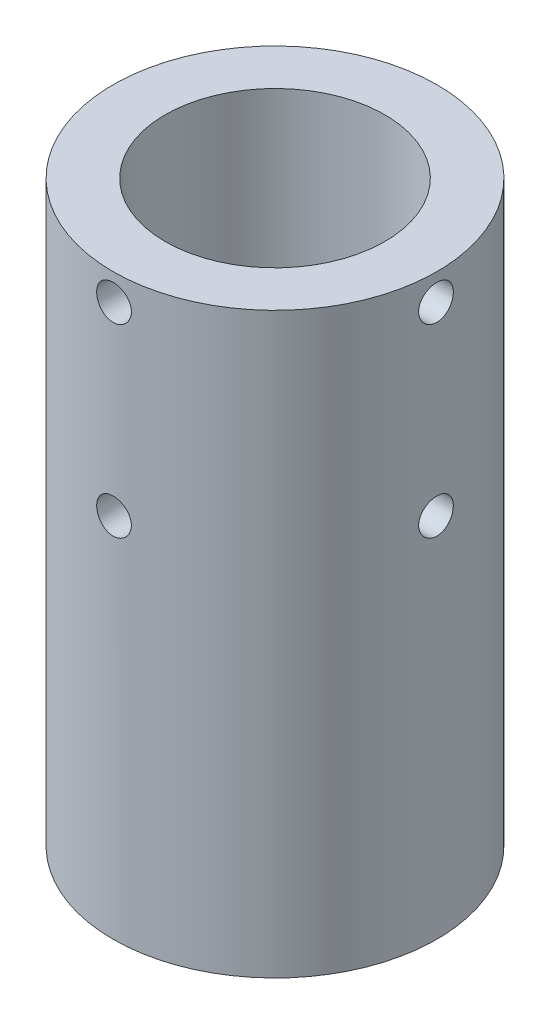
from build123d import *

# Parameters (mm, degrees)
SKETCH1_R           = 14
BOSS_EXTRUDE1_DEPTH = 50
CUT_EXTRUDE1_DEPTH  = 33
SKETCH3_R           = 9.5
CUT_EXTRUDE2_DEPTH  = 24.5
SKETCH5_R           = 1.5
CUT_EXTRUDE3_DEPTH  = 4.619168
CIRPATTERN1_COUNT   = 2
CIRPATTERN1_ANGLE   = 90


with BuildPart() as part:
    # Sketch1 → Boss-Extrude1 (new body)
    with BuildSketch(Plane(origin=(0, 0, 0), x_dir=(1, 0, 0), z_dir=(0, 1, 0))):
        with Locations(Location((0, 0, 0), (0, 0, 270))):  # turned: the seam where the file's is
            Circle(SKETCH1_R)
    extrude(amount=BOSS_EXTRUDE1_DEPTH)

    # Sketch2 → Cut-Extrude1 (cut)
    with BuildSketch(Plane(origin=(0, 0, 0), x_dir=(-1, 0, 0), z_dir=(0, -1, 0))):
        with BuildLine():
            Line((-2.397915762, -5.5), (2.397915762, -5.5))
            ThreePointArc((2.397915762, -5.5), (5.196152423, -3), (5.962097602, 0.673344034))
            Line((5.962097602, 0.673344034), (3.56418184, 4.826655966))
            ThreePointArc((3.56418184, 4.826655966), (0, 6), (-3.56418184, 4.826655966))
            Line((-3.56418184, 4.826655966), (-5.962097602, 0.673344034))
            ThreePointArc((-5.962097602, 0.673344034), (-5.196152423, -3), (-2.397915762, -5.5))
        make_face()
    extrude(amount=-CUT_EXTRUDE1_DEPTH, mode=Mode.SUBTRACT)

    # Sketch3 → Cut-Extrude2 (cut)
    with BuildSketch(Plane(origin=(0, 50, 0), x_dir=(1, 0, 0), z_dir=(0, 1, 0))):
        with Locations(Location((0, 0, 0), (0, 0, 270))):  # turned: the seam where the file's is
            Circle(SKETCH3_R)
    extrude(amount=-CUT_EXTRUDE2_DEPTH, mode=Mode.SUBTRACT)

    # Sketch5 → Cut-Extrude3 (cut)
    with BuildSketch(Plane(origin=(14, 50, 0), x_dir=(0, 0, -1), z_dir=(1, 0, 0))):
        with Locations((0, -2.3)):
            Circle(SKETCH5_R)
        with Locations((0, -18.3)):
            Circle(SKETCH5_R)
    cut_extrude3 = extrude(amount=-CUT_EXTRUDE3_DEPTH, mode=Mode.SUBTRACT)

    # CirPattern1: Cut-Extrude3 ×2 about axis
    cirpattern1_axis = Axis((0, 33, 0), (0, -1, 0))
    for i in range(1, CIRPATTERN1_COUNT):
        add(cut_extrude3.rotate(cirpattern1_axis, i * CIRPATTERN1_ANGLE / (CIRPATTERN1_COUNT - 1)), mode=Mode.SUBTRACT)


solid = part.part
